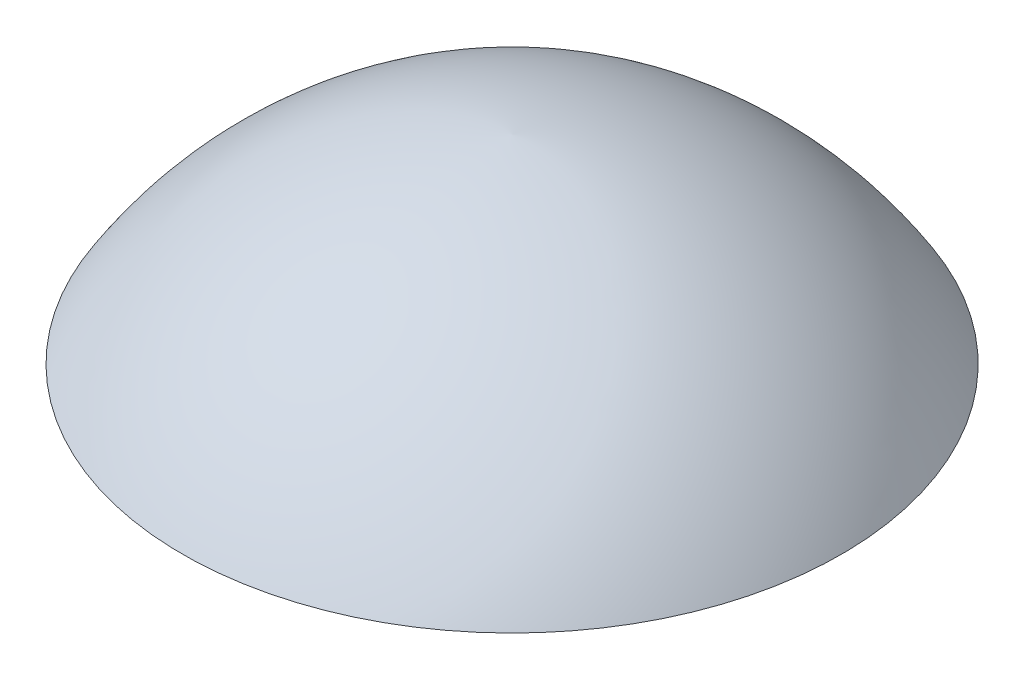
from build123d import *


with BuildPart() as part:
    # Çizim2 → Döndür1 (revolve)
    with BuildSketch(Plane.XY):
        with BuildLine():
            Line((0, 0), (0, 9.949289435))
            ThreePointArc((0, 9.949289435), (-9.463916314, 6.987815539), (-16.5, 0))
            Line((-16.5, 0), (0, 0))
        make_face()
    revolve(axis=Axis((0, 0, 0), (0, 1, 0)))


solid = part.part
